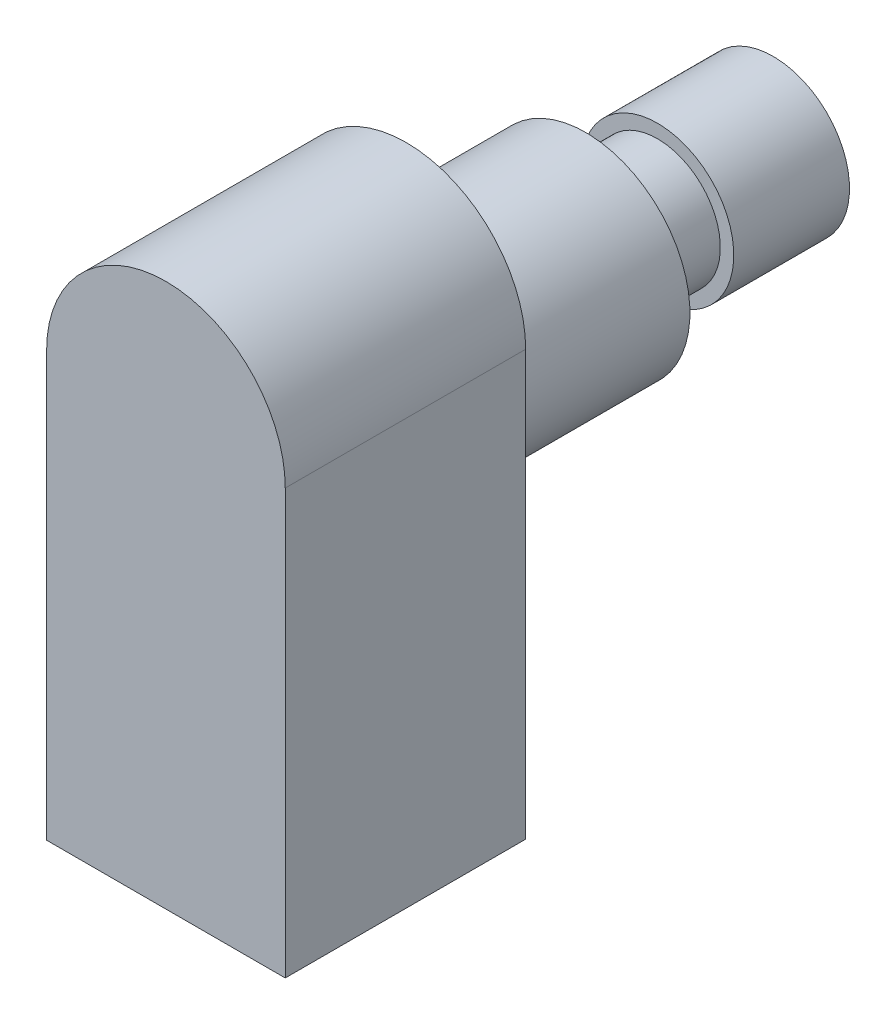
from build123d import *

# Parameters (mm, degrees)
BOSS_EXTRU_1_DEPTH = 13.4
ESQUISSE2_R        = 5.805
BOSS_EXTRU_2_DEPTH = 10
ESQUISSE3_R        = 3.5
BOSS_EXTRU_3_DEPTH = 4
ESQUISSE4_R        = 4.25
BOSS_EXTRU_4_DEPTH = 6.45


with BuildPart() as part:
    # Esquisse1 → Boss.-Extru.1 (new body)
    with BuildSketch(Plane.XY):
        with BuildLine():
            Line((-6.65, 0), (-6.65, -23.65))
            Line((-6.65, -23.65), (6.65, -23.65))
            Line((6.65, -23.65), (6.65, 0))
            ThreePointArc((6.65, 0), (0, 6.65), (-6.65, 0))
        make_face()
    extrude(amount=BOSS_EXTRU_1_DEPTH)

    # Esquisse2 → Boss.-Extru.2 (add)
    with BuildSketch(Plane(origin=(0, 0, 0), x_dir=(-1, 0, 0), z_dir=(0, 0, -1))):
        with Locations((0, -3.665)):
            Circle(ESQUISSE2_R)
    extrude(amount=BOSS_EXTRU_2_DEPTH)

    # Esquisse3 → Boss.-Extru.3 (add)
    with BuildSketch(Plane(origin=(0, 0, -10), x_dir=(-1, 0, 0), z_dir=(0, 0, -1))):
        with Locations((0, -3.665)):
            Circle(ESQUISSE3_R)
    extrude(amount=BOSS_EXTRU_3_DEPTH)

    # Esquisse4 → Boss.-Extru.4 (add)
    with BuildSketch(Plane(origin=(0, 0, -14), x_dir=(-1, 0, 0), z_dir=(0, 0, -1))):
        with Locations((0, -3.665)):
            Circle(ESQUISSE4_R)
    extrude(amount=BOSS_EXTRU_4_DEPTH)


solid = part.part
